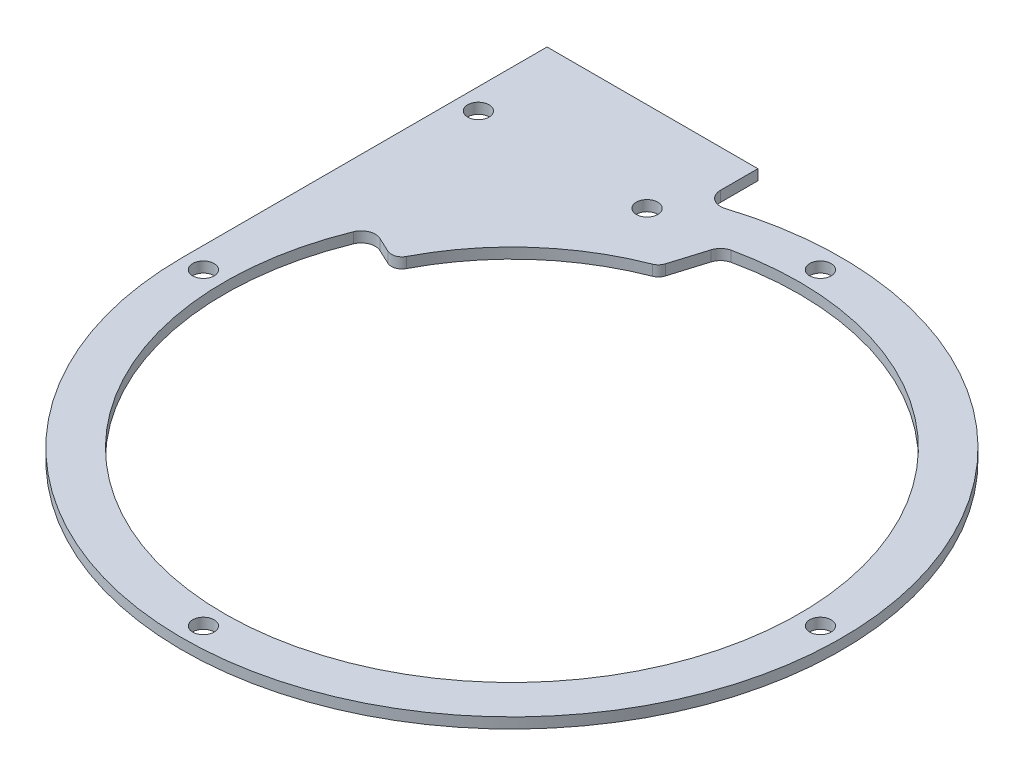
from build123d import *

# Parameters (mm, degrees)
SKETCH_1_R      = 40.9
SKETCH_1_R_2    = 1.525
EXTRUDE_1_DEPTH = 1.5
EXTRUDE_3_DEPTH = 1.5
FILLET_1_R      = 2
SKETCH_3_W      = 30
SKETCH_3_H      = 5
EXTRUDE_4_DEPTH = 1.5


with BuildPart() as part:
    # 草图1 → 凸台-拉伸1 (new body)
    with BuildSketch(Plane(origin=(0, 0, 0), x_dir=(1, 0, 0), z_dir=(0, 1, 0))):
        with BuildLine():
            Line((-46.9, 0), (-46.9, 46.9))
            Line((-46.9, 46.9), (-16.9, 46.9))
            Line((-16.9, 46.9), (-16.9, 46.574671228))
            ThreePointArc((-16.9, 46.574671228), (-16.079234093, 44.95930534), (-14.290593047, 44.669776699))
            ThreePointArc((-14.290593047, 44.669776699), (37.88033008, -27.65303949), (-46.9, 0))
        make_face()
        Circle(SKETCH_1_R, mode=Mode.SUBTRACT)
        with Locations((-19.9, 39.130550724)):
            Circle(SKETCH_1_R_2, mode=Mode.SUBTRACT)
        with Locations((0, 43.9)):
            Circle(SKETCH_1_R_2, mode=Mode.SUBTRACT)
        with Locations((43.9, 0)):
            Circle(SKETCH_1_R_2, mode=Mode.SUBTRACT)
        with Locations((0, -43.9)):
            Circle(SKETCH_1_R_2, mode=Mode.SUBTRACT)
        with Locations((-43.9, 0)):
            Circle(SKETCH_1_R_2, mode=Mode.SUBTRACT)
        with Locations((-43.9, 39.130550724)):
            Circle(SKETCH_1_R_2, mode=Mode.SUBTRACT)
    extrude(amount=EXTRUDE_1_DEPTH)

    # 草图2 → 凸台-拉伸3 (add)
    with BuildSketch(Plane(origin=(0, 0, 0), x_dir=(1, 0, 0), z_dir=(0, 1, 0))):
        with BuildLine():
            Line((-37.06798849, 17.285086905), (-33.052288278, 15.412535144))
            ThreePointArc((-33.052288278, 15.412535144), (-31.934408281, 15.352211673), (-31.08609948, 16.082736681))
            ThreePointArc((-31.08609948, 16.082736681), (-23.380571231, 26.04513177), (-12.647507481, 32.634959086))
            ThreePointArc((-12.647507481, 32.634959086), (-12.090765455, 33.012479837), (-11.754991898, 33.595351795))
            Line((-11.754991898, 33.595351795), (-9.89460553, 39.685095205))
            ThreePointArc((-9.89460553, 39.685095205), (-26.015599209, 31.559445461), (-37.06798849, 17.285086905))
        make_face()
    extrude(amount=EXTRUDE_3_DEPTH)

    # 圆角1
    fillet_1_edges = [part.edges().sort_by_distance(p)[0] for p in [
        (-9.89460553, 0.75, -39.685095205),
        (-37.06798849, 0.75, -17.285086905),
    ]]
    fillet(fillet_1_edges, radius=FILLET_1_R)

    # 草图3 → 凸台-拉伸4 (add)
    with BuildSketch(Plane(origin=(0, 1.5, 0), x_dir=(1, 0, 0), z_dir=(0, 1, 0))):
        with Locations((-31.9, 49.4)):
            Rectangle(SKETCH_3_W, SKETCH_3_H)
    extrude(amount=-EXTRUDE_4_DEPTH)


solid = part.part
